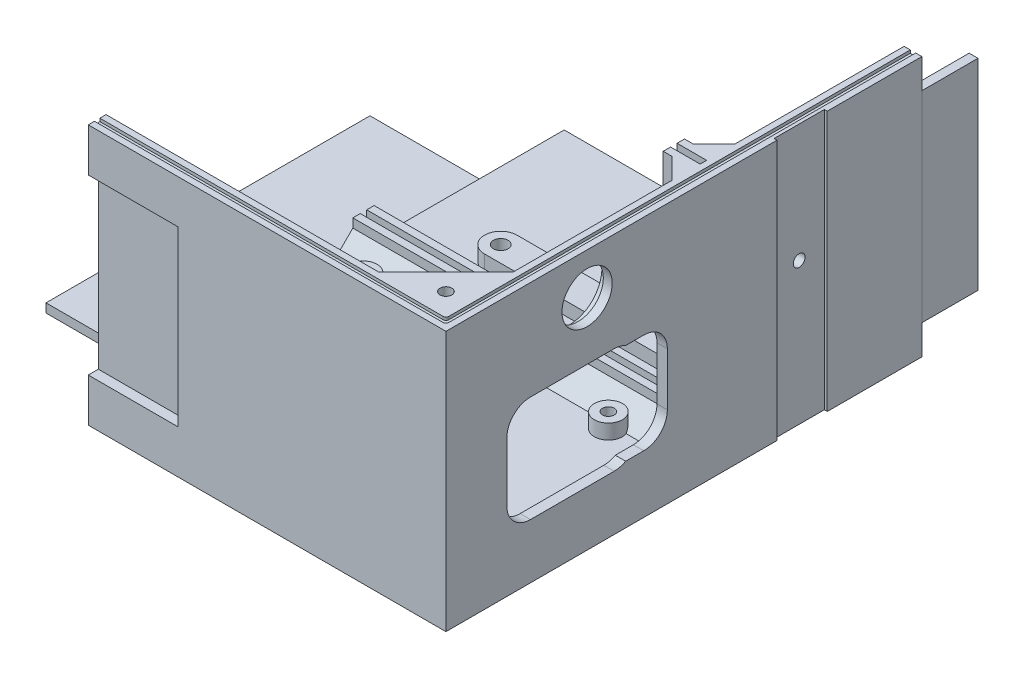
from build123d import *

# Parameters (mm, degrees)
SKETCH1_W            = 121
SKETCH1_H            = 161
BOSS_EXTRUDE1_DEPTH  = 88
SKETCH2_W            = 115
SKETCH2_H            = 155
CUT_EXTRUDE1_DEPTH   = 82
SKETCH3_W            = 71.6
SKETCH3_H            = 10
CUT_EXTRUDE2_DEPTH   = 3.4
SKETCH5_W            = 40
SKETCH5_H            = 109.6
BOSS_EXTRUDE2_DEPTH  = 3
SKETCH6_W            = 30.4
SKETCH6_H            = 58.6
CUT_EXTRUDE3_DEPTH   = 3.4
SKETCH7_W            = 19
SKETCH7_H            = 68
BOSS_EXTRUDE3_DEPTH  = 3
SKETCH8_R            = 8.5
CUT_EXTRUDE4_DEPTH   = 162
SKETCH9_W            = 2.5
SKETCH9_H            = 82
BOSS_EXTRUDE4_DEPTH  = 10
SKETCH10_W           = 105
SKETCH10_H           = 2.5
BOSS_EXTRUDE5_DEPTH  = 10
BOSS_EXTRUDE6_DEPTH  = 9
SKETCH12_R           = 2
CUT_EXTRUDE6_DEPTH   = 5
BOSS_EXTRUDE7_DEPTH  = 73
SKETCH14_R           = 4.75
BOSS_EXTRUDE8_DEPTH  = 5
SKETCH15_R           = 2
CUT_EXTRUDE7_DEPTH   = 5
SKETCH16_R           = 4.75
BOSS_EXTRUDE9_DEPTH  = 5
SKETCH17_R           = 2
CUT_EXTRUDE8_DEPTH   = 5
SKETCH18_R           = 2.5
CUT_EXTRUDE9_DEPTH   = 6
BOSS_EXTRUDE10_DEPTH = 82
SKETCH20_R           = 4.75
SKETCH20_R_2         = 2
BOSS_EXTRUDE11_DEPTH = 5
BOSS_EXTRUDE12_REACH = 123
BOSS_EXTRUDE13_REACH = 123
BOSS_EXTRUDE14_REACH = 163
BOSS_EXTRUDE15_REACH = 182
BOSS_EXTRUDE16_REACH = 123
BOSS_EXTRUDE17_DEPTH = 5
CUT_EXTRUDE10_DEPTH  = 1
SKETCH29_R           = 11
CUT_EXTRUDE11_DEPTH  = 3
SKETCH31_W           = 69.5
SKETCH31_H           = 47
CUT_EXTRUDE12_DEPTH  = 2.5
CUT_EXTRUDE13_DEPTH  = 3.5
SKETCH33_W           = 17
SKETCH33_H           = 88
CUT_EXTRUDE14_DEPTH  = 1
BOSS_EXTRUDE19_DEPTH = 2
FILLET1_R            = 1
FILLET2_R            = 1
SKETCH35_R           = 2
CUT_EXTRUDE15_DEPTH  = 5
SKETCH36_W           = 17
SKETCH36_H           = 45
BOSS_EXTRUDE20_DEPTH = 1


with BuildPart() as part:
    # Sketch1 → Boss-Extrude1 (new body)
    with BuildSketch(Plane(origin=(0, 0, 0), x_dir=(1, 0, 0), z_dir=(0, 1, 0))):
        with Locations((60.5, -80.5)):
            Rectangle(SKETCH1_W, SKETCH1_H)
    extrude(amount=BOSS_EXTRUDE1_DEPTH)

    # Sketch2 → Cut-Extrude1 (cut)
    with BuildSketch(Plane(origin=(0, 88, 0), x_dir=(1, 0, 0), z_dir=(0, 1, 0))):
        with Locations((57.5, -77.5)):
            Rectangle(SKETCH2_W, SKETCH2_H)
    extrude(amount=-CUT_EXTRUDE1_DEPTH, mode=Mode.SUBTRACT)

    # Sketch3 → Cut-Extrude2 (cut)
    with BuildSketch(Plane.XZ):
        with Locations((60.5, 5)):
            Rectangle(SKETCH3_W, SKETCH3_H)
    extrude(amount=-CUT_EXTRUDE2_DEPTH, mode=Mode.SUBTRACT)

    # Sketch5 → Boss-Extrude2 (add)
    with BuildSketch(Plane.XZ):
        with Locations((-20, 80.5)):
            Rectangle(SKETCH5_W, SKETCH5_H)
    extrude(amount=-BOSS_EXTRUDE2_DEPTH)

    # Sketch6 → Cut-Extrude3 (cut)
    with BuildSketch(Plane.XY.offset(161)):
        with Locations((15.2, 44)):
            Rectangle(SKETCH6_W, SKETCH6_H)
    extrude(amount=-CUT_EXTRUDE3_DEPTH, mode=Mode.SUBTRACT)

    # Sketch8 → Cut-Extrude4 (cut, through all)
    with BuildSketch(Plane(origin=(121, 0, 0), x_dir=(0, 0, -1), z_dir=(1, 0, 0))):
        with Locations((-113.25, 74)):
            Circle(SKETCH8_R)
    extrude(amount=-CUT_EXTRUDE4_DEPTH, mode=Mode.SUBTRACT)

    # Sketch9 → Boss-Extrude4 (add)
    with BuildSketch(Plane.ZY.offset(-115)):
        with Locations((70.25, 47)):
            Rectangle(SKETCH9_W, SKETCH9_H)
        with Locations((65.55, 47)):
            Rectangle(SKETCH9_W, SKETCH9_H)
    extrude(amount=BOSS_EXTRUDE4_DEPTH)

    # Sketch10 → Boss-Extrude5 (add)
    with BuildSketch(Plane(origin=(0, 6, 0), x_dir=(1, 0, 0), z_dir=(0, 1, 0))):
        with Locations((52.5, -65.55)):
            Rectangle(SKETCH10_W, SKETCH10_H)
        with Locations((52.5, -70.25)):
            Rectangle(SKETCH10_W, SKETCH10_H)
    extrude(amount=BOSS_EXTRUDE5_DEPTH)

    # Sketch11 → Boss-Extrude6 (add)
    with BuildSketch(Plane(origin=(0, 88, 0), x_dir=(1, 0, 0), z_dir=(0, 1, 0))):
        Polygon((115, -155), (92.372583002, -155), (115, -132.372583002), align=None)
    extrude(amount=-BOSS_EXTRUDE6_DEPTH)

    # Sketch12 → Cut-Extrude6 (cut)
    with BuildSketch(Plane(origin=(0, 88, 0), x_dir=(1, 0, 0), z_dir=(0, 1, 0))):
        with Locations((109.343145751, -149.343145751)):
            Circle(SKETCH12_R)
    extrude(amount=-CUT_EXTRUDE6_DEPTH, mode=Mode.SUBTRACT)

    # Sketch13 → Boss-Extrude7 (add)
    with BuildSketch(Plane(origin=(0, 6, 0), x_dir=(1, 0, 0), z_dir=(0, 1, 0))):
        Polygon((115, -155), (115, -148), (108, -155), align=None)
    extrude(amount=BOSS_EXTRUDE7_DEPTH)

    # Sketch14 → Boss-Extrude8 (add)
    with BuildSketch(Plane(origin=(0, 6, 0), x_dir=(1, 0, 0), z_dir=(0, 1, 0))):
        with Locations((40.53, -80.05)):
            Circle(SKETCH14_R)
        with Locations((95, -80.05)):
            Circle(SKETCH14_R)
        with Locations((40.53, -146.45)):
            Circle(SKETCH14_R)
        with Locations((95, -146.45)):
            Circle(SKETCH14_R)
    extrude(amount=BOSS_EXTRUDE8_DEPTH)

    # Sketch15 → Cut-Extrude7 (cut)
    with BuildSketch(Plane(origin=(0, 11, 0), x_dir=(1, 0, 0), z_dir=(0, 1, 0))):
        with Locations((40.53, -80.05)):
            Circle(SKETCH15_R)
        with Locations((95, -80.05)):
            Circle(SKETCH15_R)
        with Locations((40.53, -146.45)):
            Circle(SKETCH15_R)
        with Locations((95, -146.45)):
            Circle(SKETCH15_R)
    extrude(amount=-CUT_EXTRUDE7_DEPTH, mode=Mode.SUBTRACT)

    # Sketch16 → Boss-Extrude9 (add)
    with BuildSketch(Plane(origin=(0, 6, 0), x_dir=(1, 0, 0), z_dir=(0, 1, 0))):
        with Locations((85, -28.3)):
            Circle(SKETCH16_R)
        with BuildLine():
            Line((27.85, -43.8), (88, -43.8))
            ThreePointArc((88, -43.8), (93.5, -49.3), (88, -54.8))
            Line((88, -54.8), (27.85, -54.8))
            ThreePointArc((27.85, -54.8), (22.35, -49.3), (27.85, -43.8))
        make_face()
    extrude(amount=BOSS_EXTRUDE9_DEPTH)

    # Sketch17 → Cut-Extrude8 (cut)
    with BuildSketch(Plane(origin=(0, 11, 0), x_dir=(1, 0, 0), z_dir=(0, 1, 0))):
        with Locations((85, -28.3)):
            Circle(SKETCH17_R)
    extrude(amount=-CUT_EXTRUDE8_DEPTH, mode=Mode.SUBTRACT)

    # Sketch18 → Cut-Extrude9 (cut)
    with BuildSketch(Plane(origin=(0, 11, 0), x_dir=(1, 0, 0), z_dir=(0, 1, 0))):
        with Locations((88, -49.3)):
            Circle(SKETCH18_R)
        with Locations((27.85, -49.3)):
            Circle(SKETCH18_R)
    extrude(amount=-CUT_EXTRUDE9_DEPTH, mode=Mode.SUBTRACT)

    # Sketch19 → Boss-Extrude10 (add)
    with BuildSketch(Plane(origin=(0, 6, 0), x_dir=(1, 0, 0), z_dir=(0, 1, 0))):
        Polygon((115, -71.5), (108, -71.5), (115, -78.5), align=None)
        Polygon((115, -64.3), (115, -57.3), (108, -64.3), align=None)
    extrude(amount=BOSS_EXTRUDE10_DEPTH)

    # Sketch20 → Boss-Extrude11 (add)
    with BuildSketch(Plane(origin=(0, 6, 0), x_dir=(1, 0, 0), z_dir=(0, 1, 0))):
        with Locations((12.71, -80.76)):
            Circle(SKETCH20_R)
        with Locations((12.71, -80.76)):
            Circle(SKETCH20_R_2, mode=Mode.SUBTRACT)
        with Locations((12.71, -141.75)):
            Circle(SKETCH20_R)
        with Locations((12.71, -141.75)):
            Circle(SKETCH20_R_2, mode=Mode.SUBTRACT)
    extrude(amount=BOSS_EXTRUDE11_DEPTH)

    # Boss-Extrude12: up to this face of the body (flat: up to its plane)
    boss_extrude12_end = Plane(part.part.faces().sort_by_distance((111.5, 47, 75))[0])
    # Sketch21 → Boss-Extrude12 (add, up to the picked face)
    with BuildSketch(Plane.ZY, mode=Mode.PRIVATE) as boss_extrude12_sk1:
        Polygon((71.5, 6), (71.5, 13), (78.5, 6), align=None)
    boss_extrude12_tool1 = split(extrude(boss_extrude12_sk1.sketch, amount=-BOSS_EXTRUDE12_REACH, mode=Mode.PRIVATE), bisect_by=boss_extrude12_end, keep=Keep.BOTH, mode=Mode.PRIVATE)
    add(boss_extrude12_tool1.solids().sort_by_distance((0, 8.333333, 73.833333))[0])

    # Boss-Extrude13: up to this face of the body (flat: up to its plane)
    boss_extrude13_end = Plane(part.part.faces().sort_by_distance((111.5, 47, 60.8))[0])
    # Sketch22 → Boss-Extrude13 (add, up to the picked face)
    with BuildSketch(Plane.ZY, mode=Mode.PRIVATE) as boss_extrude13_sk1:
        Polygon((57.3, 6), (64.3, 13), (64.3, 6), align=None)
    boss_extrude13_tool1 = split(extrude(boss_extrude13_sk1.sketch, amount=-BOSS_EXTRUDE13_REACH, mode=Mode.PRIVATE), bisect_by=boss_extrude13_end, keep=Keep.BOTH, mode=Mode.PRIVATE)
    add(boss_extrude13_tool1.solids().sort_by_distance((0, 8.333333, 61.966667))[0])

    # Boss-Extrude14: up to this face of the body (flat: up to its plane)
    boss_extrude14_end = Plane(part.part.faces().sort_by_distance((55.768310912, 9.463378176, 60.763378176))[0])
    # Sketch23 → Boss-Extrude14 (add, up to the picked face)
    with BuildSketch(Plane(origin=(0, 0, 0), x_dir=(-1, 0, 0), z_dir=(0, 0, -1)), mode=Mode.PRIVATE) as boss_extrude14_sk1:
        Polygon((-115, 6), (-115, 13), (-108, 6), align=None)
    boss_extrude14_tool1 = split(extrude(boss_extrude14_sk1.sketch, amount=-BOSS_EXTRUDE14_REACH, mode=Mode.PRIVATE), bisect_by=boss_extrude14_end, keep=Keep.BOTH, mode=Mode.PRIVATE)
    add(boss_extrude14_tool1.solids().sort_by_distance((112.666667, 8.333333, 0))[0])

    # Boss-Extrude15: up to this face of the body (flat: up to its plane)
    boss_extrude15_end = Plane(part.part.faces().sort_by_distance((111.552016985, 48.723991507, 75.052016985))[0])
    # Sketch25 → Boss-Extrude15 (add, up to the picked face)
    with BuildSketch(Plane.XY.offset(161), mode=Mode.PRIVATE) as boss_extrude15_sk1:
        Polygon((115, 6), (115, 13), (108, 6), align=None)
    boss_extrude15_tool1 = split(extrude(boss_extrude15_sk1.sketch, amount=-BOSS_EXTRUDE15_REACH, mode=Mode.PRIVATE), bisect_by=boss_extrude15_end, keep=Keep.BOTH, mode=Mode.PRIVATE)
    add(boss_extrude15_tool1.solids().sort_by_distance((112.666667, 8.333333, 161))[0])

    # Boss-Extrude16: up to this face of the body (flat: up to its plane)
    boss_extrude16_end = Plane(part.part.faces().sort_by_distance((111.441247002, 44.220623501, 151.558752998))[0])
    # Sketch26 → Boss-Extrude16 (add, up to the picked face)
    with BuildSketch(Plane.ZY, mode=Mode.PRIVATE) as boss_extrude16_sk1:
        Polygon((155, 6), (148, 6), (155, 13), align=None)
    boss_extrude16_tool1 = split(extrude(boss_extrude16_sk1.sketch, amount=-BOSS_EXTRUDE16_REACH, mode=Mode.PRIVATE), bisect_by=boss_extrude16_end, keep=Keep.BOTH, mode=Mode.PRIVATE)
    add(boss_extrude16_tool1.solids().sort_by_distance((0, 8.333333, 152.666667))[0])

    # Sketch27 → Boss-Extrude17 (add)
    with BuildSketch(Plane(origin=(0, 6, 0), x_dir=(1, 0, 0), z_dir=(0, 1, 0))):
        with BuildLine():
            Line((80.276929737, -28.805081466), (82.5311818, -49.884831171))
            ThreePointArc((82.5311818, -49.884831171), (87.222182541, -43.855277785), (93.4138182, -48.330168829))
            Line((93.4138182, -48.330168829), (89.675570263, -27.462418534))
            ThreePointArc((89.675570263, -27.462418534), (85.671751442, -33.002260095), (80.276929737, -28.805081466))
        make_face()
    extrude(amount=BOSS_EXTRUDE17_DEPTH)

    # Sketch28 → Cut-Extrude10 (cut)
    with BuildSketch(Plane(origin=(0, 88, 0), x_dir=(1, 0, 0), z_dir=(0, 1, 0))):
        Polygon((0, -157.1), (0, -158.9), (118.9, -158.9), (118.9, 0), (117.1, 0), (117.1, -157.1), align=None)
    extrude(amount=-CUT_EXTRUDE10_DEPTH, mode=Mode.SUBTRACT)

    # Sketch29 → Cut-Extrude11 (cut)
    with BuildSketch(Plane.ZY.offset(-115)):
        with Locations((113.25, 74)):
            Circle(SKETCH29_R)
    extrude(amount=-CUT_EXTRUDE11_DEPTH, mode=Mode.SUBTRACT)

    # Sketch31 → Cut-Extrude12 (cut)
    with BuildSketch(Plane.ZY.offset(-115)):
        with Locations((113.25, 36.5)):
            Rectangle(SKETCH31_W, SKETCH31_H)
    extrude(amount=-CUT_EXTRUDE12_DEPTH, mode=Mode.SUBTRACT)

    # Sketch32 → Cut-Extrude13 (cut)
    with BuildSketch(Plane.ZY.offset(-117.5)):
        with BuildLine():
            Line((86.1, 45.45), (86.1, 27.55))
            ThreePointArc((86.1, 27.55), (88.443145751, 21.893145751), (94.1, 19.55))
            Line((94.1, 19.55), (100.2, 19.55))
            ThreePointArc((100.2, 19.55), (102.072983346, 18.804033308), (104.072983346, 18.55))
            Line((104.072983346, 18.55), (132.4, 18.55))
            ThreePointArc((132.4, 18.55), (138.056854249, 20.893145751), (140.4, 26.55))
            Line((140.4, 26.55), (140.4, 46.45))
            ThreePointArc((140.4, 46.45), (138.056854249, 52.106854249), (132.4, 54.45))
            Line((132.4, 54.45), (104.072983346, 54.45))
            ThreePointArc((104.072983346, 54.45), (102.072983346, 54.195966692), (100.2, 53.45))
            Line((100.2, 53.45), (94.1, 53.45))
            ThreePointArc((94.1, 53.45), (88.443145751, 51.106854249), (86.1, 45.45))
        make_face()
    extrude(amount=-CUT_EXTRUDE13_DEPTH, mode=Mode.SUBTRACT)

    # Sketch33 → Cut-Extrude14 (cut)
    with BuildSketch(Plane(origin=(121, 0, 0), x_dir=(0, 0, -1), z_dir=(1, 0, 0))):
        with Locations((-40.5, 44)):
            Rectangle(SKETCH33_W, SKETCH33_H)
    extrude(amount=-CUT_EXTRUDE14_DEPTH, mode=Mode.SUBTRACT)

    # Sketch34 → Boss-Extrude19 (add)
    with BuildSketch(Plane.ZY.offset(-25)):
        Polygon((133, 6), (148, 6), (155, 13), (155, 28), align=None)
    extrude(amount=-BOSS_EXTRUDE19_DEPTH)

    # Fillet1
    fillet1_edges = [part.edges().sort_by_distance(p)[0] for p in [
        (117.1, 87.5, 157.1),
    ]]
    fillet(fillet1_edges, radius=FILLET1_R)

    # Fillet2
    fillet2_edges = [part.edges().sort_by_distance(p)[0] for p in [
        (118.9, 87.5, 158.9),
    ]]
    fillet(fillet2_edges, radius=FILLET2_R)

    # Sketch35 → Cut-Extrude15 (cut)
    with BuildSketch(Plane(origin=(120, 0, 0), x_dir=(0, 0, -1), z_dir=(1, 0, 0))):
        with Locations((-40.5, 48)):
            Circle(SKETCH35_R)
    extrude(amount=-CUT_EXTRUDE15_DEPTH, mode=Mode.SUBTRACT)

    # Sketch36 → Boss-Extrude20 (add)
    with BuildSketch(Plane.ZY.offset(-115)):
        with Locations((40.5, 35.5)):
            Rectangle(SKETCH36_W, SKETCH36_H)
    extrude(amount=BOSS_EXTRUDE20_DEPTH)


with BuildPart() as body_2:
    # Sketch7 → Boss-Extrude3 (new body)
    with BuildSketch(Plane(origin=(121, 0, 0), x_dir=(0, 0, -1), z_dir=(1, 0, 0))):
        with Locations((9.5, 44)):
            Rectangle(SKETCH7_W, SKETCH7_H)
    extrude(amount=-BOSS_EXTRUDE3_DEPTH)


solid = Compound([part.part, body_2.part])
